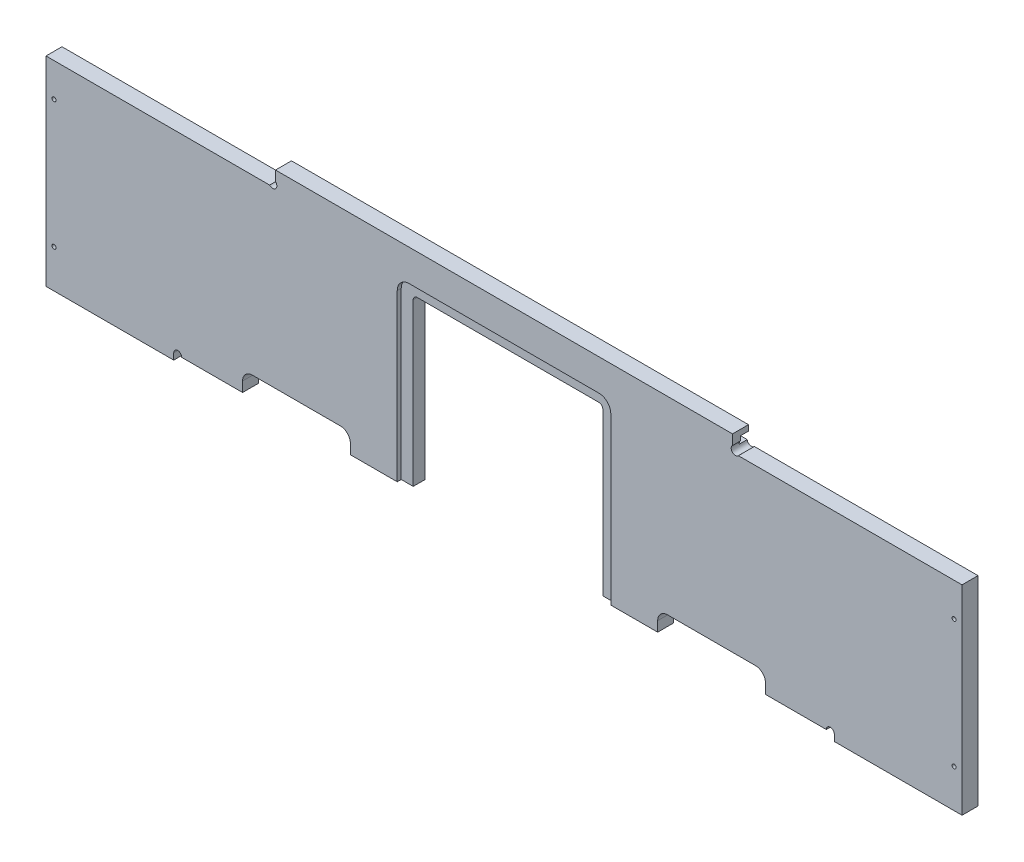
from build123d import *

# Parameters (mm, degrees)
EXTRUDE1_DEPTH     = 12.7
SKETCH6_R          = 3.302
CUT_EXTRUDE4_DEPTH = 12.7
CUT_EXTRUDE1_DEPTH = 3.175
SKETCH4_R          = 1.5875
CUT_EXTRUDE2_DEPTH = 12.7
SKETCH5_W          = 363.5375
SKETCH5_H          = 6.35
CUT_EXTRUDE3_DEPTH = 6.35
SKETCH7_W          = 101.6
SKETCH7_H          = 5.08
EXTRUDE2_DEPTH     = 12.7
SKETCH8_R          = 3.175
CUT_EXTRUDE5_DEPTH = 12.7


with BuildPart() as part:
    # Sketch2 → Extrude1 (new body)
    with BuildSketch(Plane.XY):
        with BuildLine():
            Line((-5740.4, 1537.97), (-5740.4, 1384.3))
            Line((-5740.4, 1384.3), (-5584.03125, 1384.3))
            Line((-5584.03125, 1384.3), (-5584.03125, 1392.2375))
            ThreePointArc((-5584.03125, 1392.2375), (-5581.706410076, 1397.850160076), (-5576.09375, 1400.175))
            Line((-5576.09375, 1400.175), (-5506.24375, 1400.175))
            ThreePointArc((-5506.24375, 1400.175), (-5500.631089924, 1397.850160076), (-5498.30625, 1392.2375))
            Line((-5498.30625, 1392.2375), (-5498.30625, 1384.3))
            Line((-5498.30625, 1384.3), (-5451.475, 1384.3))
            Line((-5451.475, 1384.3), (-5451.475, 1512.8875))
            ThreePointArc((-5451.475, 1512.8875), (-5450.54506403, 1515.13256403), (-5448.3, 1516.0625))
            Line((-5448.3, 1516.0625), (-5303.8375, 1516.0625))
            ThreePointArc((-5303.8375, 1516.0625), (-5301.59243597, 1515.13256403), (-5300.6625, 1512.8875))
            Line((-5300.6625, 1512.8875), (-5300.6625, 1384.3))
            Line((-5300.6625, 1384.3), (-5253.83125, 1384.3))
            Line((-5253.83125, 1384.3), (-5253.83125, 1392.2375))
            ThreePointArc((-5253.83125, 1392.2375), (-5251.506410076, 1397.850160076), (-5245.89375, 1400.175))
            Line((-5245.89375, 1400.175), (-5176.04375, 1400.175))
            ThreePointArc((-5176.04375, 1400.175), (-5170.431089924, 1397.850160076), (-5168.10625, 1392.2375))
            Line((-5168.10625, 1392.2375), (-5168.10625, 1384.3))
            Line((-5168.10625, 1384.3), (-5011.7375, 1384.3))
            Line((-5011.7375, 1384.3), (-5011.7375, 1537.97))
            Line((-5011.7375, 1537.97), (-5194.3, 1537.97))
            Line((-5194.3, 1537.97), (-5194.3, 1550.67))
            Line((-5194.3, 1550.67), (-5557.8375, 1550.67))
            Line((-5557.8375, 1550.67), (-5557.8375, 1537.97))
            Line((-5557.8375, 1537.97), (-5740.4, 1537.97))
        make_face()
    extrude(amount=-EXTRUDE1_DEPTH)

    # Sketch6 → Cut-Extrude4 (cut)
    with BuildSketch(Plane.XY):
        with Locations((-5560.08256403, 1540.21506403)):
            Circle(SKETCH6_R)
        with Locations((-5192.05493597, 1540.21506403)):
            Circle(SKETCH6_R)
    extrude(amount=-CUT_EXTRUDE4_DEPTH, mode=Mode.SUBTRACT)

    # Sketch3 → Cut-Extrude1 (cut)
    with BuildSketch(Plane.XY):
        with BuildLine():
            Line((-5297.4875, 1377.95), (-5454.65, 1377.95))
            ThreePointArc((-5454.65, 1377.95), (-5459.140128061, 1379.809871939), (-5461, 1384.3))
            Line((-5461, 1384.3), (-5461, 1516.0625))
            ThreePointArc((-5461, 1516.0625), (-5458.210192091, 1522.797692091), (-5451.475, 1525.5875))
            Line((-5451.475, 1525.5875), (-5300.6625, 1525.5875))
            ThreePointArc((-5300.6625, 1525.5875), (-5293.927307909, 1522.797692091), (-5291.1375, 1516.0625))
            Line((-5291.1375, 1516.0625), (-5291.1375, 1384.3))
            ThreePointArc((-5291.1375, 1384.3), (-5292.997371939, 1379.809871939), (-5297.4875, 1377.95))
        make_face()
    extrude(amount=-CUT_EXTRUDE1_DEPTH, mode=Mode.SUBTRACT)

    # Sketch4 → Cut-Extrude2 (cut)
    with BuildSketch(Plane.XY):
        with Locations((-5734.05, 1511.3)):
            Circle(SKETCH4_R)
        with Locations((-5734.05, 1409.7)):
            Circle(SKETCH4_R)
        with Locations((-5018.0875, 1409.7)):
            Circle(SKETCH4_R)
        with Locations((-5018.0875, 1511.3)):
            Circle(SKETCH4_R)
    extrude(amount=-CUT_EXTRUDE2_DEPTH, mode=Mode.SUBTRACT)

    # Sketch5 → Cut-Extrude3 (cut)
    with BuildSketch(Plane(origin=(0, 0, -12.7), x_dir=(-1, 0, 0), z_dir=(0, 0, -1))):
        with Locations((5376.06875, 1543.05)):
            Rectangle(SKETCH5_W, SKETCH5_H)
    extrude(amount=-CUT_EXTRUDE3_DEPTH, mode=Mode.SUBTRACT)

    # Sketch7 → Extrude2 (add)
    with BuildSketch(Plane.XY):
        with Locations((-5689.6, 1381.76)):
            Rectangle(SKETCH7_W, SKETCH7_H)
        with Locations((-5062.5375, 1381.76)):
            Rectangle(SKETCH7_W, SKETCH7_H)
    extrude(amount=-EXTRUDE2_DEPTH)

    # Sketch8 → Cut-Extrude5 (cut)
    with BuildSketch(Plane.XY):
        with Locations((-5635.625, 1384.3)):
            Circle(SKETCH8_R)
        with Locations((-5116.5125, 1384.3)):
            Circle(SKETCH8_R)
    extrude(amount=-CUT_EXTRUDE5_DEPTH, mode=Mode.SUBTRACT)


solid = part.part
